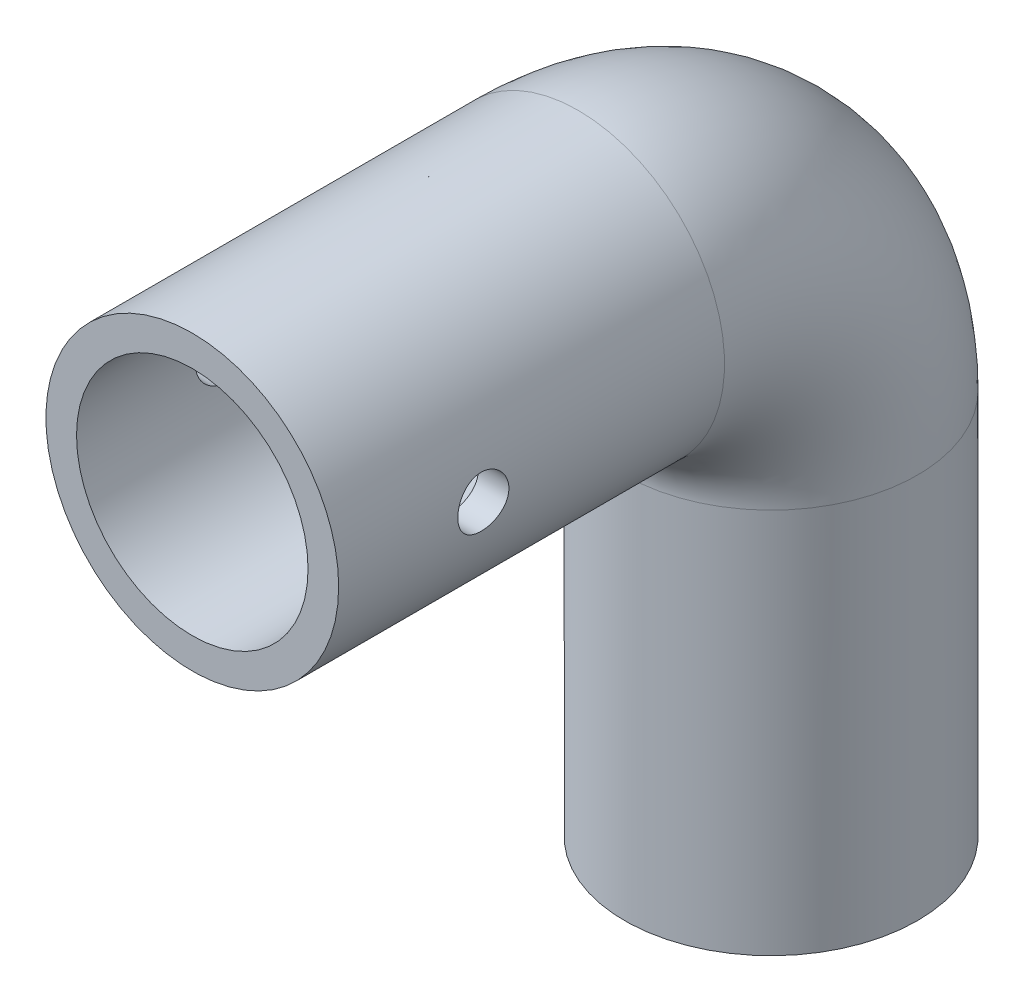
from build123d import *

# Parameters (mm, degrees)
SKETCH1_R   = 15.175
SKETCH1_R_2 = 12
SKETCH6_W   = 2.65
SKETCH6_H   = 15.175


with BuildPart() as part:
    # Sweep1: sweep along a path in Sketch3
    with BuildLine(Plane(origin=(0, 0, 0), x_dir=(0, 0, -1), z_dir=(1, 0, 0))) as sweep1_path:
        Line((0, 0), (40, 0))
        ThreePointArc((40, 0), (54.142135624, -5.857864376), (60, -20))
        Line((60, -20), (60, -60))
    # Sketch1 → Sweep1 (sweep)
    with BuildSketch(Plane.XY):
        Circle(SKETCH1_R)
        Circle(SKETCH1_R_2, mode=Mode.SUBTRACT)
    sweep(path=sweep1_path.line)

    # Sketch6 → M5 Clearance Hole1 (revolve, cut)
    with BuildSketch(Plane(origin=(0, 0, -15), x_dir=(0, 0, 1), z_dir=(0, 1, 0))):
        with Locations((1.325, 7.5875)):
            Rectangle(SKETCH6_W, SKETCH6_H)
    m5_clearance_hole1 = revolve(axis=Axis((-6.35, 0, -15), (1, 0, 0)), mode=Mode.SUBTRACT)

    # Mirror1: M5 Clearance Hole1 across plane
    add(m5_clearance_hole1.mirror(Plane(origin=(0, 0, 0), x_dir=(0, 0, 1), z_dir=(1, 0, 0))), mode=Mode.SUBTRACT)


solid = part.part
